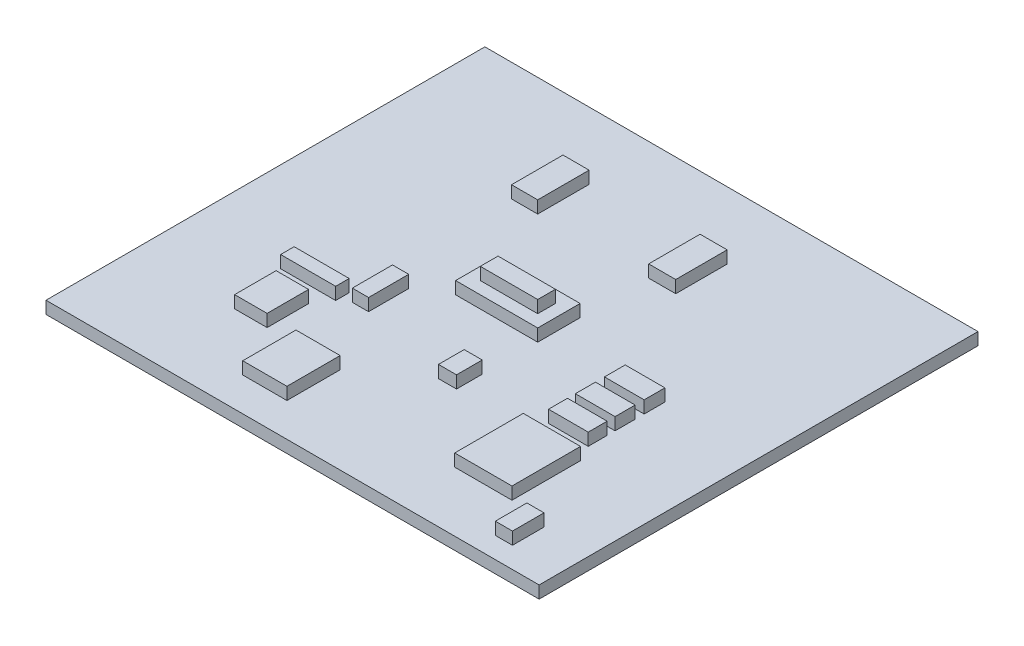
from build123d import *

# Parameters (mm, degrees)
CROQUIS1_W              = 40
CROQUIS1_H              = 35.6
SALIENTE_EXTRUIR1_DEPTH = 1
CROQUIS2_W              = 6.658598016
CROQUIS2_H              = 3.439056118
CROQUIS2_W_2            = 4.643913986
CROQUIS2_H_2            = 5.561026915
CROQUIS2_W_3            = 2.634170644
CROQUIS2_H_3            = 3.365884712
CROQUIS2_W_4            = 4.463455813
CROQUIS2_H_4            = 1.097571101
CROQUIS2_W_5            = 1.317085322
CROQUIS2_H_5            = 3.256127602
CROQUIS2_W_6            = 3.585398932
CROQUIS2_H_6            = 4.317112999
CROQUIS2_W_7            = 2.121970796
CROQUIS2_H_7            = 4.170770186
CROQUIS2_W_8            = 2.195142203
CROQUIS2_W_9            = 1.390256729
CROQUIS2_H_8            = 2.560999237
CROQUIS2_W_10           = 3.219541898
CROQUIS2_H_9            = 1.536599542
CROQUIS2_H_10           = 1.628063801
CROQUIS2_H_11           = 1.682942356
CROQUIS2_W_11           = 1.463428135
CROQUIS2_H_12           = 2.085385093
SALIENTE_EXTRUIR2_DEPTH = 1
CROQUIS3_W              = 4.658598016
CROQUIS3_H              = 1.439056118
SALIENTE_EXTRUIR3_DEPTH = 1


with BuildPart() as part:
    # Croquis1 → Saliente-Extruir1 (new body)
    with BuildSketch(Plane(origin=(0, 0, 0), x_dir=(1, 0, 0), z_dir=(0, 1, 0))):
        with Locations((-12.948868654, -4.565292662)):
            Rectangle(CROQUIS1_W, CROQUIS1_H)
    extrude(amount=SALIENTE_EXTRUIR1_DEPTH)

    # Croquis2 → Saliente-Extruir2 (add)
    with BuildSketch(Plane(origin=(0, 1, 0), x_dir=(1, 0, 0), z_dir=(0, 1, 0))):
        with Locations((-13.387897095, -3.650650078)):
            Rectangle(CROQUIS2_W, CROQUIS2_H)
        with Locations((-2.321956993, -14.736118204)):
            Rectangle(CROQUIS2_W_2, CROQUIS2_H_2)
        with Locations((-23.375794119, -13.638547102)):
            Rectangle(CROQUIS2_W_3, CROQUIS2_H_3)
        with Locations((-23.412379823, -10.089733874)):
            Rectangle(CROQUIS2_W_4, CROQUIS2_H_4)
        with Locations((-19.717223781, -8.461670073)):
            Rectangle(CROQUIS2_W_5, CROQUIS2_H_5)
        with Locations((-17.924524315, -17.480045957)):
            Rectangle(CROQUIS2_W_6, CROQUIS2_H_6)
        with Locations((-20.119666518, 5.715289989)):
            Rectangle(CROQUIS2_W_7, CROQUIS2_H_7)
        with Locations((-8.961026986, 5.715289989)):
            Rectangle(CROQUIS2_W_8, CROQUIS2_H_7)
        with Locations((2.490298175, -19.382502534)):
            Rectangle(CROQUIS2_W_9, CROQUIS2_H_8)
        with Locations((-2.302428969, -9.870219653)):
            Rectangle(CROQUIS2_W_10, CROQUIS2_H_9)
        with Locations((-2.302428969, -7.647638173)):
            Rectangle(CROQUIS2_W_10, CROQUIS2_H_10)
        with Locations((-2.302428969, -5.260421027)):
            Rectangle(CROQUIS2_W_10, CROQUIS2_H_11)
        with Locations((-10.790312155, -10.9129122)):
            Rectangle(CROQUIS2_W_11, CROQUIS2_H_12)
    extrude(amount=SALIENTE_EXTRUIR2_DEPTH)

    # Croquis3 → Saliente-Extruir3 (add)
    with BuildSketch(Plane(origin=(0, 2, 0), x_dir=(1, 0, 0), z_dir=(0, 1, 0))):
        with Locations((-13.387897095, -3.650650078)):
            Rectangle(CROQUIS3_W, CROQUIS3_H)
    extrude(amount=SALIENTE_EXTRUIR3_DEPTH)


solid = part.part
